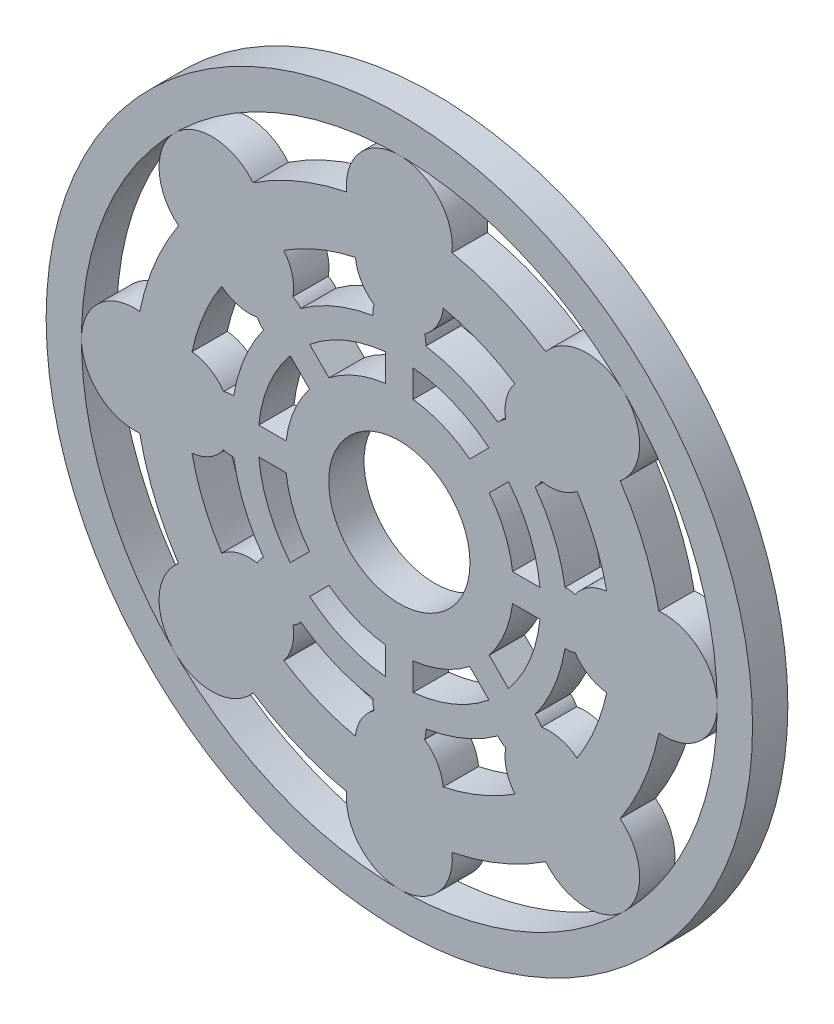
from build123d import *

# Parameters (mm, degrees)
SKETCH1_R             = 20
BOSS_EXTRUDE1_DEPTH   = 10
SKETCH1_R_2           = 100
BOSS_EXTRUDE1_2_DEPTH = 10


with BuildPart() as part:
    # Sketch1 → Boss-Extrude1 (new body)
    with BuildSketch(Plane.XY):
        with BuildLine():
            ThreePointArc((-62.525783877, -41.418912958), (-68.014199687, -52.282066996), (-63.639610261, -63.639610353))
            ThreePointArc((-63.639610261, -63.639610353), (-52.28206693, -68.014199684), (-41.418912958, -62.525783877))
            ThreePointArc((-41.418912958, -62.525783877), (-28.701257427, -69.290964938), (-14.924811557, -73.5))
            ThreePointArc((-14.924811557, -73.5), (-11.124297699, -85.062305934), (9.4e-08, -90))
            ThreePointArc((9.4e-08, -90), (11.124297762, -85.062305864), (14.924811557, -73.5))
            ThreePointArc((14.924811557, -73.5), (28.701257427, -69.290964938), (41.418912958, -62.525783877))
            ThreePointArc((41.418912958, -62.525783877), (52.282066931, -68.014199684), (63.639610262, -63.639610352))
            ThreePointArc((63.639610262, -63.639610352), (68.014199687, -52.282066995), (62.525783877, -41.418912958))
            ThreePointArc((62.525783877, -41.418912958), (69.290964938, -28.701257427), (73.5, -14.924811557))
            ThreePointArc((73.5, -14.924811557), (85.062305899, -11.124297731), (90, 0))
            ThreePointArc((90, 0), (85.062305899, 11.124297731), (73.5, 14.924811557))
            ThreePointArc((73.5, 14.924811557), (69.290964938, 28.701257427), (62.525783877, 41.418912958))
            ThreePointArc((62.525783877, 41.418912958), (68.014199686, 52.282066963), (63.639610307, 63.639610307))
            ThreePointArc((63.639610307, 63.639610307), (52.282066963, 68.014199686), (41.418912958, 62.525783877))
            ThreePointArc((41.418912958, 62.525783877), (28.701257427, 69.290964938), (14.924811557, 73.5))
            ThreePointArc((14.924811557, 73.5), (11.124297731, 85.062305899), (0, 90))
            ThreePointArc((0, 90), (-11.124297731, 85.062305899), (-14.924811557, 73.5))
            ThreePointArc((-14.924811557, 73.5), (-28.701257427, 69.290964938), (-41.418912958, 62.525783877))
            ThreePointArc((-41.418912958, 62.525783877), (-52.282067039, 68.014199689), (-63.639610415, 63.639610199))
            ThreePointArc((-63.639610415, 63.639610199), (-68.014199682, 52.282066887), (-62.525783877, 41.418912958))
            ThreePointArc((-62.525783877, 41.418912958), (-69.290964938, 28.701257427), (-73.5, 14.924811557))
            ThreePointArc((-73.5, 14.924811557), (-85.062305842, 11.124297782), (-90, 1.52e-07))
            ThreePointArc((-90, 1.52e-07), (-85.062305955, -11.12429768), (-73.5, -14.924811557))
            ThreePointArc((-73.5, -14.924811557), (-69.290964938, -28.701257427), (-62.525783877, -41.418912958))
        make_face()
        with BuildLine():
            ThreePointArc((-46.907894737, -7.476590891), (-43.884277794, -18.177463037), (-38.455638579, -27.88214234))
            ThreePointArc((-38.455638579, -27.88214234), (-39.454261392, -28.915104147), (-40.23758895, -30.119535778))
            ThreePointArc((-40.23758895, -30.119535778), (-45.549402712, -30.32281662), (-50.29644514, -32.714944693))
            ThreePointArc((-50.29644514, -32.714944693), (-55.432771951, -22.961005942), (-58.697916667, -12.43199819))
            ThreePointArc((-58.697916667, -12.43199819), (-53.649760793, -10.76682228), (-49.75, -7.154544011))
            ThreePointArc((-49.75, -7.154544011), (-48.344441998, -7.452309556), (-46.907894737, -7.476590891))
        make_face(mode=Mode.SUBTRACT)
        with BuildLine():
            ThreePointArc((58.697916667, 12.43199819), (53.649760793, 10.76682228), (49.75, 7.154544011))
            ThreePointArc((49.75, 7.154544011), (48.344441998, 7.452309556), (46.907894737, 7.476590891))
            ThreePointArc((46.907894737, 7.476590891), (43.884277794, 18.177463037), (38.455638579, 27.88214234))
            ThreePointArc((38.455638579, 27.88214234), (39.454261392, 28.915104147), (40.23758895, 30.119535778))
            ThreePointArc((40.23758895, 30.119535778), (45.549402712, 30.32281662), (50.29644514, 32.714944693))
            ThreePointArc((50.29644514, 32.714944693), (55.432771951, 22.961005942), (58.697916667, 12.43199819))
        make_face(mode=Mode.SUBTRACT)
        with BuildLine():
            Line((39.808783679, 3.906499965), (32.060781687, 3.906499965))
            ThreePointArc((32.060781687, 3.906499965), (29.839370469, 12.359871941), (25.432708758, 19.908083525))
            Line((25.432708758, 19.908083525), (30.911373507, 25.386748274))
            ThreePointArc((30.911373507, 25.386748274), (36.9551813, 15.307337295), (39.808783679, 3.906499965))
        make_face(mode=Mode.SUBTRACT)
        with BuildLine():
            ThreePointArc((32.714944693, 50.29644514), (30.32281662, 45.549402712), (30.119535778, 40.23758895))
            ThreePointArc((30.119535778, 40.23758895), (28.915104147, 39.454261392), (27.88214234, 38.455638579))
            ThreePointArc((27.88214234, 38.455638579), (18.177463037, 43.884277794), (7.476590891, 46.907894737))
            ThreePointArc((7.476590891, 46.907894737), (7.452309556, 48.344441998), (7.154544011, 49.75))
            ThreePointArc((7.154544011, 49.75), (10.76682228, 53.649760793), (12.43199819, 58.697916667))
            ThreePointArc((12.43199819, 58.697916667), (22.961005942, 55.432771951), (32.714944693, 50.29644514))
        make_face(mode=Mode.SUBTRACT)
        with BuildLine():
            ThreePointArc((50.29644514, -32.714944693), (45.549402712, -30.32281662), (40.23758895, -30.119535778))
            ThreePointArc((40.23758895, -30.119535778), (39.454261392, -28.915104147), (38.455638579, -27.88214234))
            ThreePointArc((38.455638579, -27.88214234), (43.884277794, -18.177463037), (46.907894737, -7.476590891))
            ThreePointArc((46.907894737, -7.476590891), (48.344441998, -7.452309556), (49.75, -7.154544011))
            ThreePointArc((49.75, -7.154544011), (53.649760793, -10.76682228), (58.697916667, -12.43199819))
            ThreePointArc((58.697916667, -12.43199819), (55.432771951, -22.961005942), (50.29644514, -32.714944693))
        make_face(mode=Mode.SUBTRACT)
        with BuildLine():
            ThreePointArc((-12.43199819, 58.697916667), (-10.76682228, 53.649760793), (-7.154544011, 49.75))
            ThreePointArc((-7.154544011, 49.75), (-7.452309556, 48.344441998), (-7.476590891, 46.907894737))
            ThreePointArc((-7.476590891, 46.907894737), (-18.177463037, 43.884277794), (-27.88214234, 38.455638579))
            ThreePointArc((-27.88214234, 38.455638579), (-28.915104147, 39.454261392), (-30.119535778, 40.23758895))
            ThreePointArc((-30.119535778, 40.23758895), (-30.32281662, 45.549402712), (-32.714944693, 50.29644514))
            ThreePointArc((-32.714944693, 50.29644514), (-22.961005942, 55.432771951), (-12.43199819, 58.697916667))
        make_face(mode=Mode.SUBTRACT)
        with BuildLine():
            ThreePointArc((19.908083525, 25.432708758), (12.359871941, 29.839370469), (3.906499965, 32.060781687))
            Line((3.906499965, 32.060781687), (3.906499965, 39.808783679))
            ThreePointArc((3.906499965, 39.808783679), (15.307337295, 36.9551813), (25.386748274, 30.911373507))
            Line((25.386748274, 30.911373507), (19.908083525, 25.432708758))
        make_face(mode=Mode.SUBTRACT)
        with BuildLine():
            ThreePointArc((12.43199819, -58.697916667), (10.76682228, -53.649760793), (7.154544011, -49.75))
            ThreePointArc((7.154544011, -49.75), (7.452309556, -48.344441998), (7.476590891, -46.907894737))
            ThreePointArc((7.476590891, -46.907894737), (18.177463037, -43.884277794), (27.88214234, -38.455638579))
            ThreePointArc((27.88214234, -38.455638579), (28.915104147, -39.454261392), (30.119535778, -40.23758895))
            ThreePointArc((30.119535778, -40.23758895), (30.32281662, -45.549402712), (32.714944693, -50.29644514))
            ThreePointArc((32.714944693, -50.29644514), (22.961005942, -55.432771951), (12.43199819, -58.697916667))
        make_face(mode=Mode.SUBTRACT)
        with BuildLine():
            ThreePointArc((-50.29644514, 32.714944693), (-45.549402712, 30.32281662), (-40.23758895, 30.119535778))
            ThreePointArc((-40.23758895, 30.119535778), (-39.454261392, 28.915104147), (-38.455638579, 27.88214234))
            ThreePointArc((-38.455638579, 27.88214234), (-43.884277794, 18.177463037), (-46.907894737, 7.476590891))
            ThreePointArc((-46.907894737, 7.476590891), (-48.344441998, 7.452309556), (-49.75, 7.154544011))
            ThreePointArc((-49.75, 7.154544011), (-53.649760793, 10.76682228), (-58.697916667, 12.43199819))
            ThreePointArc((-58.697916667, 12.43199819), (-55.432771951, 22.961005942), (-50.29644514, 32.714944693))
        make_face(mode=Mode.SUBTRACT)
        with BuildLine():
            ThreePointArc((39.808783679, -3.906499965), (36.9551813, -15.307337295), (30.911373507, -25.386748274))
            Line((30.911373507, -25.386748274), (25.432708758, -19.908083525))
            ThreePointArc((25.432708758, -19.908083525), (29.839370469, -12.359871941), (32.060781687, -3.906499965))
            Line((32.060781687, -3.906499965), (39.808783679, -3.906499965))
        make_face(mode=Mode.SUBTRACT)
        with BuildLine():
            ThreePointArc((-32.714944693, -50.29644514), (-30.32281662, -45.549402712), (-30.119535778, -40.23758895))
            ThreePointArc((-30.119535778, -40.23758895), (-28.915104147, -39.454261392), (-27.88214234, -38.455638579))
            ThreePointArc((-27.88214234, -38.455638579), (-18.177463037, -43.884277794), (-7.476590891, -46.907894737))
            ThreePointArc((-7.476590891, -46.907894737), (-7.452309556, -48.344441998), (-7.154544011, -49.75))
            ThreePointArc((-7.154544011, -49.75), (-10.76682228, -53.649760793), (-12.43199819, -58.697916667))
            ThreePointArc((-12.43199819, -58.697916667), (-22.961005942, -55.432771951), (-32.714944693, -50.29644514))
        make_face(mode=Mode.SUBTRACT)
        with BuildLine():
            ThreePointArc((-3.906499965, 32.060781687), (-12.359871941, 29.839370469), (-19.908083525, 25.432708758))
            Line((-19.908083525, 25.432708758), (-25.386748274, 30.911373507))
            ThreePointArc((-25.386748274, 30.911373507), (-15.307337295, 36.9551813), (-3.906499965, 39.808783679))
            Line((-3.906499965, 39.808783679), (-3.906499965, 32.060781687))
        make_face(mode=Mode.SUBTRACT)
        with BuildLine():
            ThreePointArc((25.386748274, -30.911373507), (15.307337295, -36.9551813), (3.906499965, -39.808783679))
            Line((3.906499965, -39.808783679), (3.906499965, -32.060781687))
            ThreePointArc((3.906499965, -32.060781687), (12.359871941, -29.839370469), (19.908083525, -25.432708758))
            Line((19.908083525, -25.432708758), (25.386748274, -30.911373507))
        make_face(mode=Mode.SUBTRACT)
        with BuildLine():
            ThreePointArc((-25.432708758, 19.908083525), (-29.839370469, 12.359871941), (-32.060781687, 3.906499965))
            Line((-32.060781687, 3.906499965), (-39.808783679, 3.906499965))
            ThreePointArc((-39.808783679, 3.906499965), (-36.9551813, 15.307337295), (-30.911373507, 25.386748274))
            Line((-30.911373507, 25.386748274), (-25.432708758, 19.908083525))
        make_face(mode=Mode.SUBTRACT)
        with BuildLine():
            ThreePointArc((-3.906499965, -39.808783679), (-15.307337295, -36.9551813), (-25.386748274, -30.911373507))
            Line((-25.386748274, -30.911373507), (-19.908083525, -25.432708758))
            ThreePointArc((-19.908083525, -25.432708758), (-12.359871941, -29.839370469), (-3.906499965, -32.060781687))
            Line((-3.906499965, -32.060781687), (-3.906499965, -39.808783679))
        make_face(mode=Mode.SUBTRACT)
        with BuildLine():
            ThreePointArc((-32.060781687, -3.906499965), (-29.839370469, -12.359871941), (-25.432708758, -19.908083525))
            Line((-25.432708758, -19.908083525), (-30.911373507, -25.386748274))
            ThreePointArc((-30.911373507, -25.386748274), (-36.9551813, -15.307337295), (-39.808783679, -3.906499965))
            Line((-39.808783679, -3.906499965), (-32.060781687, -3.906499965))
        make_face(mode=Mode.SUBTRACT)
        Circle(SKETCH1_R, mode=Mode.SUBTRACT)
    extrude(amount=BOSS_EXTRUDE1_DEPTH)


with BuildPart() as body_2:
    # Sketch1 → Boss-Extrude1 2 (new body)
    with BuildSketch(Plane.XY):
        Circle(SKETCH1_R_2)
        with BuildLine():
            ThreePointArc((9.4e-08, -90), (-34.441508839, -83.149157957), (-63.639610261, -63.639610353))
            ThreePointArc((-63.639610261, -63.639610353), (-83.149157943, -34.441508873), (-90, 1.52e-07))
            ThreePointArc((-90, 1.52e-07), (-83.149157926, 34.441508913), (-63.639610415, 63.639610199))
            ThreePointArc((-63.639610415, 63.639610199), (-34.441508983, 83.149157897), (0, 90))
            ThreePointArc((0, 90), (34.441508913, 83.149157926), (63.639610307, 63.639610307))
            ThreePointArc((63.639610307, 63.639610307), (83.149157926, 34.441508913), (90, 0))
            ThreePointArc((90, 0), (83.149157914, -34.441508942), (63.639610262, -63.639610352))
            ThreePointArc((63.639610262, -63.639610352), (34.441508927, -83.14915792), (9.4e-08, -90))
        make_face(mode=Mode.SUBTRACT)
    extrude(amount=BOSS_EXTRUDE1_2_DEPTH)


solid = Compound([part.part, body_2.part])
